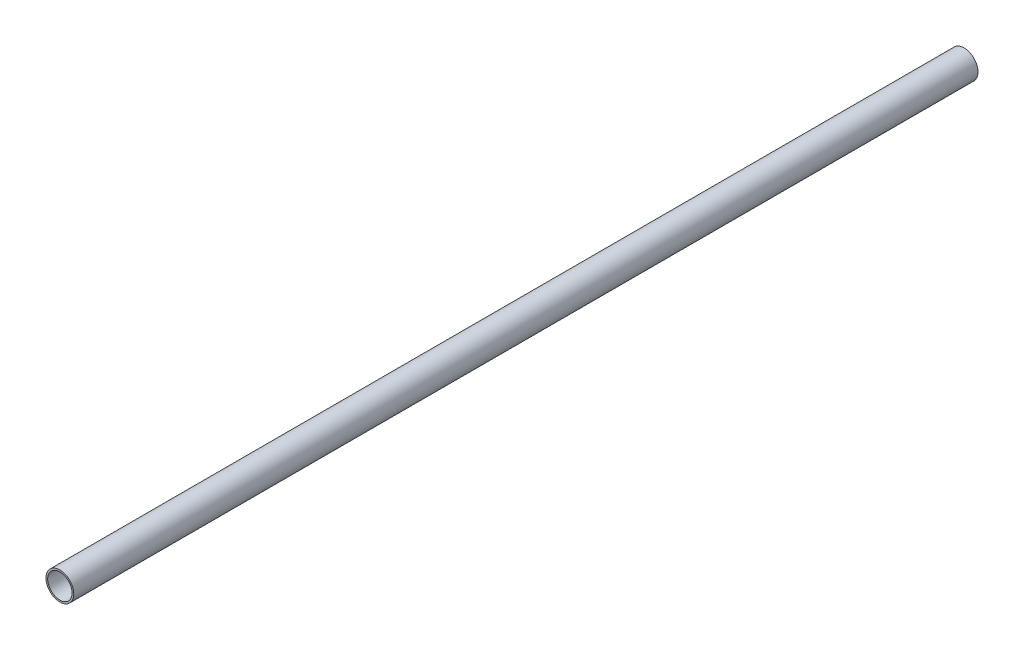
from build123d import *

# Parameters (mm, degrees)
SKETCH1_R           = 7.239
SKETCH1_R_2         = 6.35
BOSS_EXTRUDE1_DEPTH = 470.8


with BuildPart() as part:
    # Sketch1 → Boss-Extrude1 (new body)
    with BuildSketch(Plane.XY):
        Circle(SKETCH1_R)
        Circle(SKETCH1_R_2, mode=Mode.SUBTRACT)
    extrude(amount=BOSS_EXTRUDE1_DEPTH)


solid = part.part
